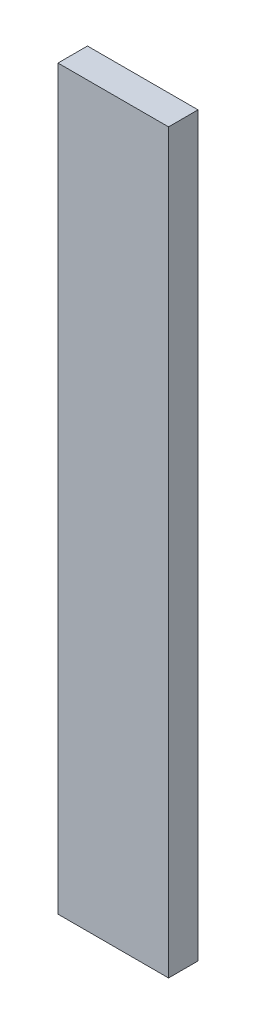
from build123d import *

# Parameters (mm, degrees)
SKETCH_1_W      = 60
SKETCH_1_H      = 400
EXTRUDE_1_DEPTH = 16


with BuildPart() as part:
    # 草图1 → 凸台-拉伸1 (new body)
    with BuildSketch(Plane.XY):
        Rectangle(SKETCH_1_W, SKETCH_1_H)
    extrude(amount=EXTRUDE_1_DEPTH)


solid = part.part
